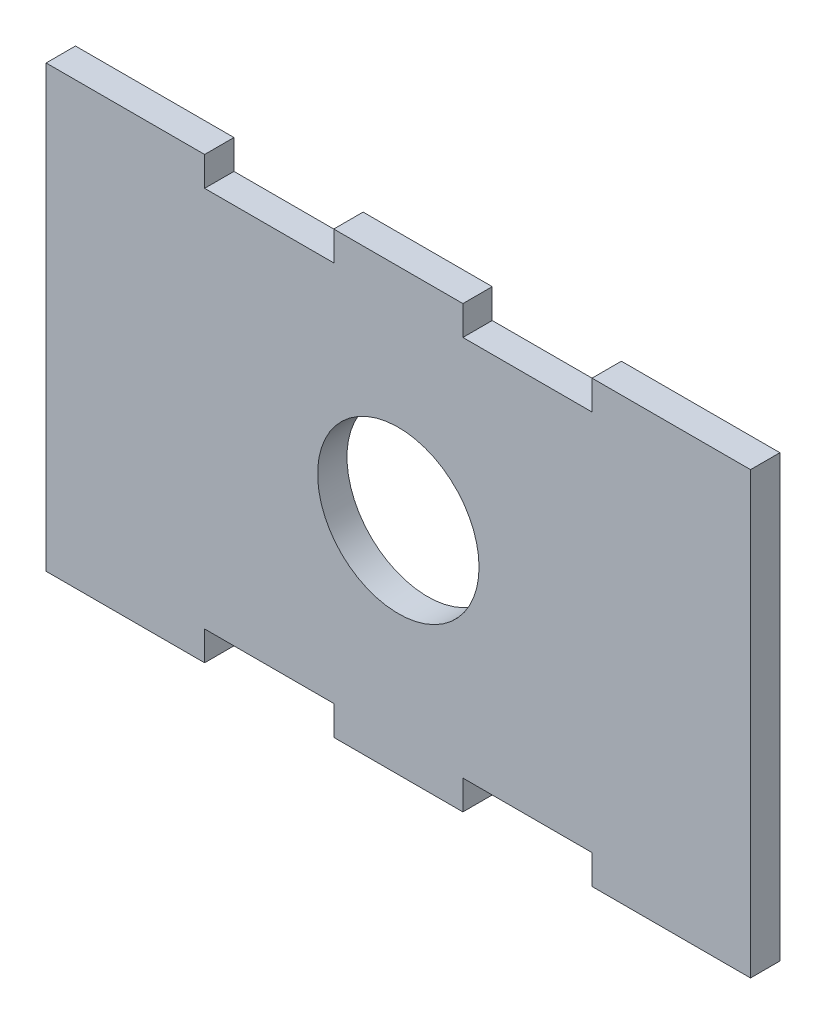
from build123d import *

# Parameters (mm, degrees)
SKETCH1_R           = 11
BOSS_EXTRUDE1_DEPTH = 4


with BuildPart() as part:
    # Sketch1 → Boss-Extrude1 (new body)
    with BuildSketch(Plane.XY):
        Polygon((-53.875885035, 42.361111111), (-32.275885035, 42.361111111), (-32.275885035, 38.361111111), (-14.675885035, 38.361111111), (-14.675885035, 42.361111111), (2.924114965, 42.361111111), (2.924114965, 38.361111111), (20.524114965, 38.361111111), (20.524114965, 42.361111111), (42.124114965, 42.361111111), (42.124114965, -17.638888889), (20.524114965, -17.638888889), (20.524114965, -13.638888889), (2.924114965, -13.638888889), (2.924114965, -17.638888889), (-14.675885035, -17.638888889), (-14.675885035, -13.638888889), (-32.275885035, -13.638888889), (-32.275885035, -17.638888889), (-53.875885035, -17.638888889), align=None)
        with Locations((-5.875885035, 12.361111111)):
            Circle(SKETCH1_R, mode=Mode.SUBTRACT)
    extrude(amount=BOSS_EXTRUDE1_DEPTH)


solid = part.part
